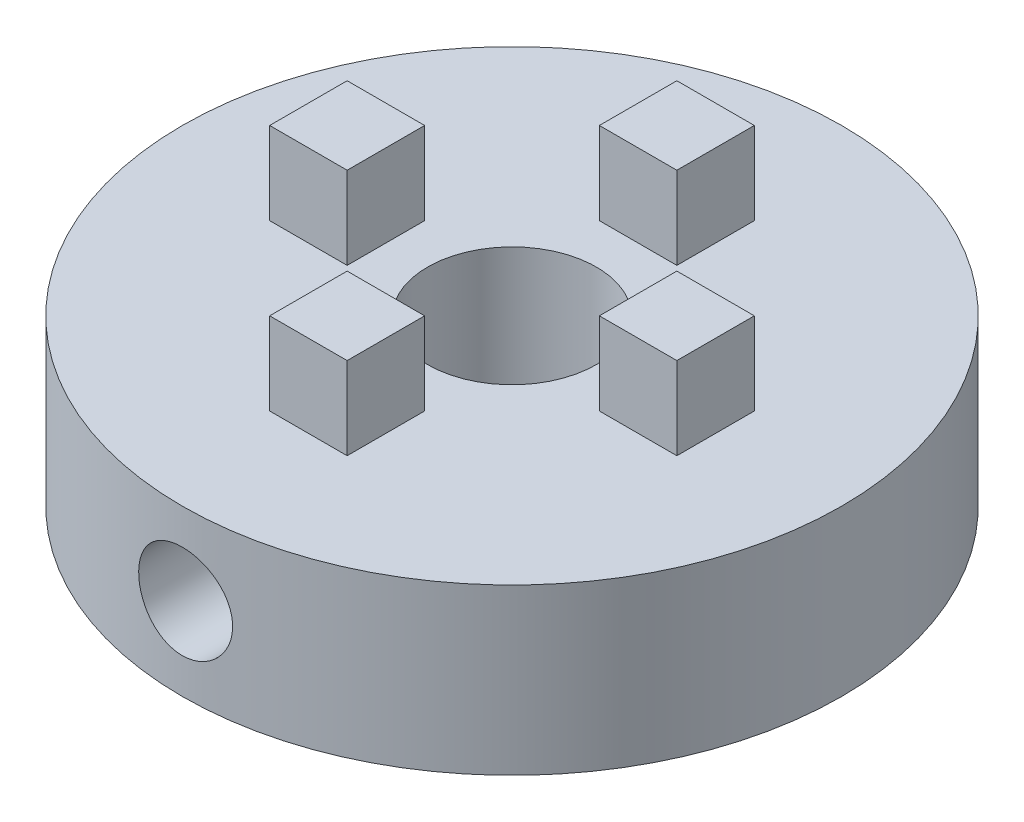
from build123d import *

# Parameters (mm, degrees)
SKETCH1_R           = 20
SKETCH1_R_2         = 5.125
BOSS_EXTRUDE1_DEPTH = 10
SKETCH2_W           = 4.7
SKETCH2_H           = 4.7
BOSS_EXTRUDE2_DEPTH = 5
SKETCH3_R           = 2
CUT_EXTRUDE2_DEPTH  = 21
CUT_EXTRUDE3_START  = 10
SKETCH4_R           = 2.85
CUT_EXTRUDE3_DEPTH  = 11.000000127


with BuildPart() as part:
    # Sketch1 → Boss-Extrude1 (new body)
    with BuildSketch(Plane(origin=(0, 0, 0), x_dir=(1, 0, 0), z_dir=(0, 1, 0))):
        Circle(SKETCH1_R)
        Circle(SKETCH1_R_2, mode=Mode.SUBTRACT)
    extrude(amount=BOSS_EXTRUDE1_DEPTH)

    # Sketch2 → Boss-Extrude2 (add)
    with BuildSketch(Plane(origin=(0, 10, 0), x_dir=(1, 0, 0), z_dir=(0, 1, 0))):
        with Locations((10, 0)):
            Rectangle(SKETCH2_W, SKETCH2_H)
        with Locations((0, 10)):
            Rectangle(SKETCH2_W, SKETCH2_H)
        with Locations((0, -10)):
            Rectangle(SKETCH2_W, SKETCH2_H)
        with Locations((-10, 0)):
            Rectangle(SKETCH2_W, SKETCH2_H)
    extrude(amount=BOSS_EXTRUDE2_DEPTH)

    # Sketch3 → Cut-Extrude2 (cut, through all)
    with BuildSketch(Plane.XY):
        with Locations((0, 5)):
            Circle(SKETCH3_R)
    extrude(amount=CUT_EXTRUDE2_DEPTH, mode=Mode.SUBTRACT)

    # Sketch4 → Cut-Extrude3 (cut, through all)
    with BuildSketch(Plane.XY.offset(CUT_EXTRUDE3_START)):
        with Locations((0, 5)):
            Circle(SKETCH4_R)
    extrude(amount=CUT_EXTRUDE3_DEPTH, mode=Mode.SUBTRACT)


solid = part.part
